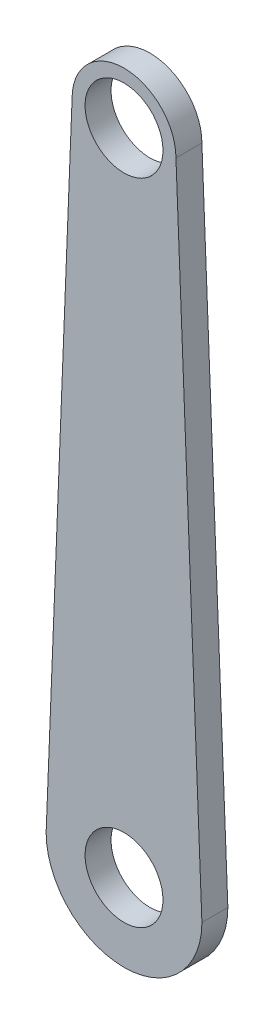
from build123d import *

# Parameters (mm, degrees)
SZKIC1_R                    = 3
DODANIE_WYCI_GNI_CIE1_DEPTH = 2


with BuildPart() as part:
    # Szkic1 → Dodanie-wyciągnięcie1 (new body)
    with BuildSketch(Plane.XY):
        with BuildLine():
            ThreePointArc((16.690895301, 15.0061262), (12.690895301, 19.0061262), (8.690895301, 15.0061262))
            Line((8.690895301, 15.0061262), (6.71006463, -34.514640573))
            Line((6.71006463, -34.514640573), (6.690895301, -34.9938738))
            ThreePointArc((6.690895301, -34.9938738), (12.690895301, -40.9938738), (18.690895301, -34.9938738))
            Line((18.690895301, -34.9938738), (18.671725971, -34.514640573))
            Line((18.671725971, -34.514640573), (16.690895301, 15.0061262))
        make_face()
        with Locations((12.690895301, -34.9938738)):
            Circle(SZKIC1_R, mode=Mode.SUBTRACT)
        with Locations((12.690895301, 15.0061262)):
            Circle(SZKIC1_R, mode=Mode.SUBTRACT)
    extrude(amount=DODANIE_WYCI_GNI_CIE1_DEPTH)


solid = part.part
